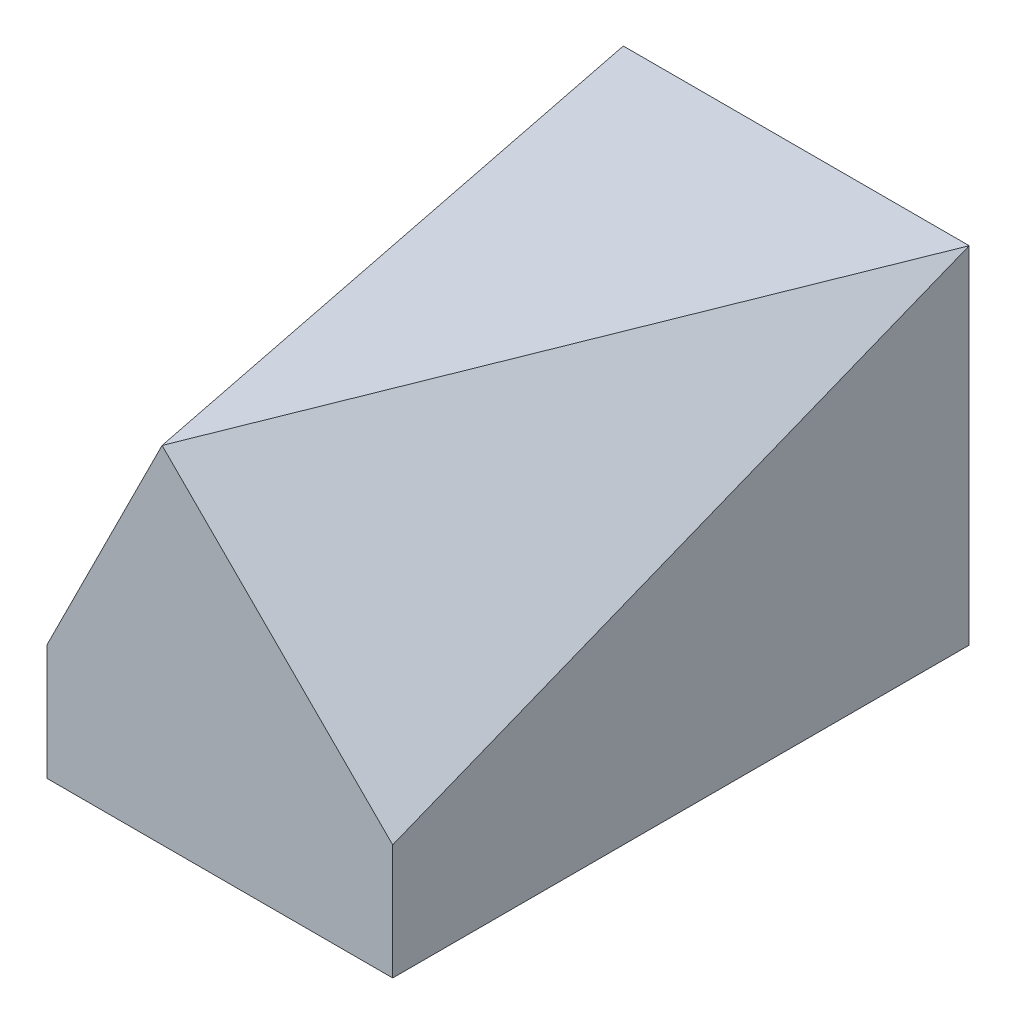
from build123d import *

# Parameters (mm, degrees)
SKETCH_1_W          = 15
SKETCH_1_H          = 25
EXTRUDE_1_DEPTH     = 15
SKETCH_4_W          = 33.460320445
SKETCH_4_H          = 26.687965621
CUT_EXTRUDE_1_DEPTH = 15
SKETCH_5_W          = 41.021028331
SKETCH_5_H          = 23.23593172
CUT_EXTRUDE_2_DEPTH = 15
SCALE_1_SCALE       = 0.2


with BuildPart() as part:
    # 草圖1 → 填料-伸長1 (new body)
    with BuildSketch(Plane(origin=(0, 0, 0), x_dir=(1, 0, 0), z_dir=(0, 1, 0))):
        Rectangle(SKETCH_1_W, SKETCH_1_H)
    extrude(amount=EXTRUDE_1_DEPTH)

    # 草圖4 → 除料-伸長1 (cut)
    with BuildSketch(Plane(origin=(-9.689922481, 4.84496124, 1.937984496), x_dir=(0.157499846, -0.078749923, 0.984374039), z_dir=(-0.880450906, 0.440225453, 0.176090181))):
        with Locations((1.566467167, 5.33065366)):
            Rectangle(SKETCH_4_W, SKETCH_4_H)
    extrude(amount=CUT_EXTRUDE_1_DEPTH, mode=Mode.SUBTRACT)

    # 草圖5 → 除料-伸長2 (cut)
    with BuildSketch(Plane(origin=(8.101851852, 8.101851852, 3.240740741), x_dir=(-0.19245009, -0.19245009, 0.962250449), z_dir=(-0.680413817, -0.680413817, -0.272165527))):
        with Locations((-1.846019689, 5.465840721)):
            Rectangle(SKETCH_5_W, SKETCH_5_H)
    extrude(amount=-CUT_EXTRUDE_2_DEPTH, mode=Mode.SUBTRACT)


with BuildPart() as part_1:
    # 縮放比例1: scaled about (-0.15625, 6.875, -0.78125)
    add(part.part.scale(SCALE_1_SCALE).moved(Location((-0.125, 5.5, -0.625))))


solid = part_1.part
